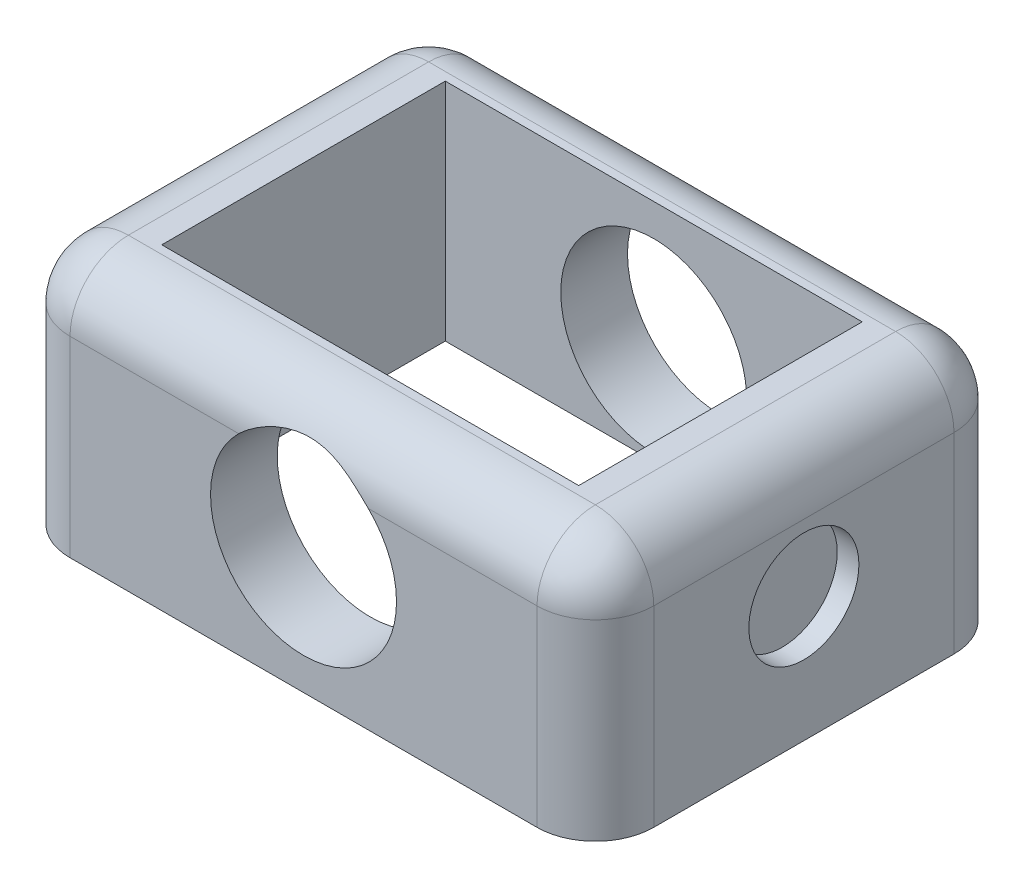
from build123d import *

# Parameters (mm, degrees)
SKETCH1_W               = 70
SKETCH1_H               = 50
BOSS_EXTRUDE1_DEPTH     = 15
SKETCH2_W               = 50
SKETCH2_H               = 34
CUT_EXTRUDE1_DEPTH      = 1
CUT_EXTRUDE1_DEPTH_BACK = 31
FILLET1_R               = 7
CHAMFER1_SIZE           = 3
SKETCH3_R               = 11.15
CUT_EXTRUDE2_DEPTH      = 1
CUT_EXTRUDE2_DEPTH_BACK = 51
SKETCH4_R               = 6.6
CUT_EXTRUDE3_DEPTH      = 2.6


with BuildPart() as part:
    # Sketch1 → Boss-Extrude1 (new body, symmetric)
    with BuildSketch(Plane(origin=(0, 0, 0), x_dir=(1, 0, 0), z_dir=(0, 1, 0))):
        Rectangle(SKETCH1_W, SKETCH1_H)
    extrude(amount=BOSS_EXTRUDE1_DEPTH, both=True)

    # Sketch2 → Cut-Extrude1 (cut, two sides)
    with BuildSketch(Plane.XZ.offset(15)) as cut_extrude1_sk:
        Rectangle(SKETCH2_W, SKETCH2_H)
    extrude(amount=CUT_EXTRUDE1_DEPTH, mode=Mode.SUBTRACT)
    extrude(cut_extrude1_sk.sketch, amount=-CUT_EXTRUDE1_DEPTH_BACK, mode=Mode.SUBTRACT)

    # Fillet1
    fillet1_edges = [part.edges().sort_by_distance(p)[0] for p in [
        (-35, 15, 0),
        (0, 15, 25),
        (35, 15, 0),
        (0, 15, -25),
        (35, 0, 25),
        (-35, 0, 25),
        (-35, 0, -25),
        (35, 0, -25),
    ]]
    fillet(fillet1_edges, radius=FILLET1_R)

    # Chamfer1
    chamfer1_edges = [part.edges().sort_by_distance(p)[0] for p in [
        (0, -15, 17),
        (-25, -15, 0),
        (0, -15, -17),
        (25, -15, 0),
    ]]
    chamfer(chamfer1_edges, length=CHAMFER1_SIZE)

    # Sketch3 → Cut-Extrude2 (cut, two sides)
    with BuildSketch(Plane(origin=(0, 0, -25), x_dir=(-1, 0, 0), z_dir=(0, 0, -1))) as cut_extrude2_sk:
        Circle(SKETCH3_R)
    extrude(amount=CUT_EXTRUDE2_DEPTH, mode=Mode.SUBTRACT)
    extrude(cut_extrude2_sk.sketch, amount=-CUT_EXTRUDE2_DEPTH_BACK, mode=Mode.SUBTRACT)

    # Sketch4 → Cut-Extrude3 (cut)
    with BuildSketch(Plane(origin=(35, 0, 0), x_dir=(0, 0, -1), z_dir=(1, 0, 0))):
        Circle(SKETCH4_R)
    cut_extrude3 = extrude(amount=-CUT_EXTRUDE3_DEPTH, mode=Mode.SUBTRACT)

    # Mirror1: Cut-Extrude3 across plane
    add(cut_extrude3.mirror(Plane(origin=(0, 0, 0), x_dir=(0, 0, 1), z_dir=(1, 0, 0))), mode=Mode.SUBTRACT)


solid = part.part
